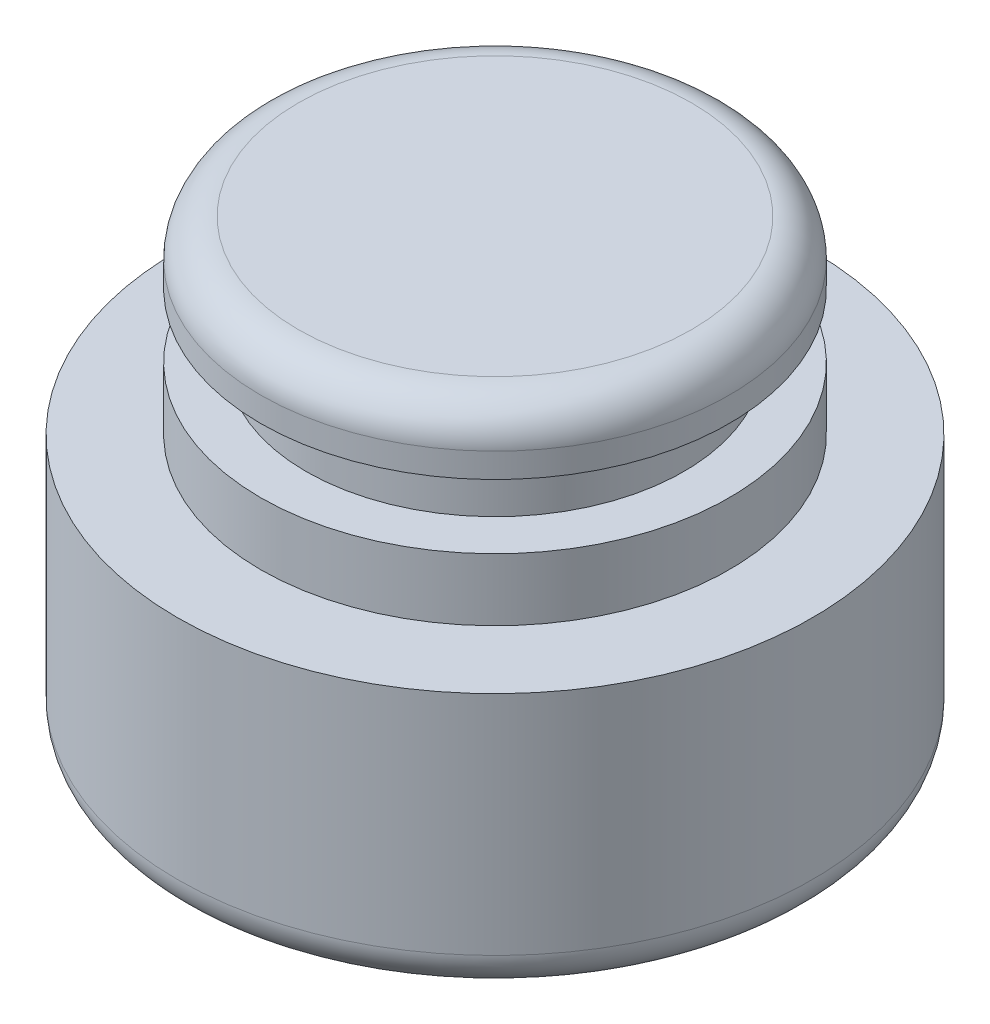
from build123d import *

# Parameters (mm, degrees)
FILLET1_R = 1
FILLET2_R = 1


with BuildPart() as part:
    # Sketch1 → Revolve1 (revolve)
    with BuildSketch(Plane.XY):
        Polygon((0, 0), (0, 12), (6.2, 12), (6.2, 10.35), (5, 10.35), (5, 8.65), (6.2, 8.65), (6.2, 7), (8.4, 7), (8.4, 0), align=None)
    revolve(axis=Axis((0, 0, 0), (0, 1, 0)))

    # Fillet1
    fillet1_edges = [part.edges().sort_by_distance(p)[0] for p in [
        (-6.2, 12, 0),
    ]]
    fillet(fillet1_edges, radius=FILLET1_R)

    # Fillet2
    fillet2_edges = [part.edges().sort_by_distance(p)[0] for p in [
        (-8.4, 0, 0),
    ]]
    fillet(fillet2_edges, radius=FILLET2_R)


solid = part.part
